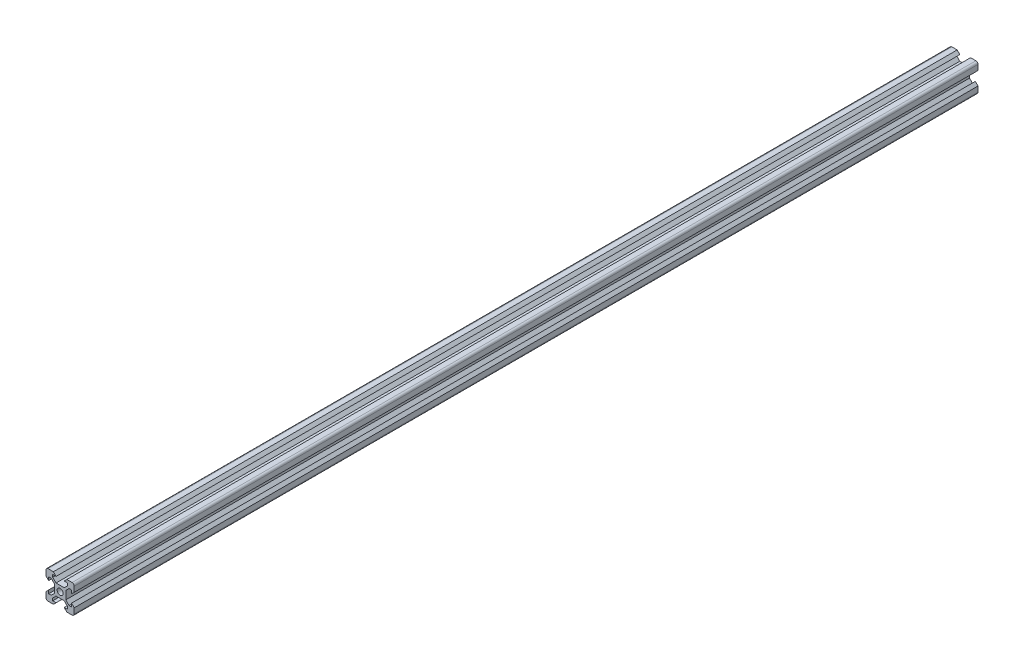
from build123d import *

# Parameters (mm, degrees)
SKETCH1_R           = 2.125
BOSS_EXTRUDE1_DEPTH = 640


with BuildPart() as part:
    # Sketch1 → Boss-Extrude1 (new body)
    with BuildSketch(Plane.XY):
        with BuildLine():
            Line((8.1, 5.225), (8.1, 2.85))
            Line((8.1, 2.85), (10, 4.75))
            Line((10, 4.75), (10, 8.5))
            ThreePointArc((10, 8.5), (9.560660172, 9.560660172), (8.5, 10))
            Line((8.5, 10), (4.75, 10))
            Line((4.75, 10), (2.85, 8.1))
            Line((2.85, 8.1), (5.225, 8.1))
            Line((5.225, 8.1), (5.225, 6.325))
            Line((5.225, 6.325), (2.9, 4))
            Line((2.9, 4), (-2.9, 4))
            Line((-2.9, 4), (-5.225, 6.325))
            Line((-5.225, 6.325), (-5.225, 8.1))
            Line((-5.225, 8.1), (-2.85, 8.1))
            Line((-2.85, 8.1), (-4.75, 10))
            Line((-4.75, 10), (-8.5, 10))
            ThreePointArc((-8.5, 10), (-9.560660172, 9.560660172), (-10, 8.5))
            Line((-10, 8.5), (-10, 4.75))
            Line((-10, 4.75), (-8.1, 2.85))
            Line((-8.1, 2.85), (-8.1, 5.225))
            Line((-8.1, 5.225), (-6.325, 5.225))
            Line((-6.325, 5.225), (-4, 2.9))
            Line((-4, 2.9), (-4, -2.9))
            Line((-4, -2.9), (-6.325, -5.225))
            Line((-6.325, -5.225), (-8.1, -5.225))
            Line((-8.1, -5.225), (-8.1, -2.85))
            Line((-8.1, -2.85), (-10, -4.75))
            Line((-10, -4.75), (-10, -8.5))
            ThreePointArc((-10, -8.5), (-9.560660172, -9.560660172), (-8.5, -10))
            Line((-8.5, -10), (-4.75, -10))
            Line((-4.75, -10), (-2.85, -8.1))
            Line((-2.85, -8.1), (-5.225, -8.1))
            Line((-5.225, -8.1), (-5.225, -6.325))
            Line((-5.225, -6.325), (-2.9, -4))
            Line((-2.9, -4), (2.9, -4))
            Line((2.9, -4), (5.225, -6.325))
            Line((5.225, -6.325), (5.225, -8.1))
            Line((5.225, -8.1), (2.85, -8.1))
            Line((2.85, -8.1), (4.75, -10))
            Line((4.75, -10), (8.5, -10))
            ThreePointArc((8.5, -10), (9.560660172, -9.560660172), (10, -8.5))
            Line((10, -8.5), (10, -4.75))
            Line((10, -4.75), (8.1, -2.85))
            Line((8.1, -2.85), (8.1, -5.225))
            Line((8.1, -5.225), (6.325, -5.225))
            Line((6.325, -5.225), (4, -2.9))
            Line((4, -2.9), (4, 2.9))
            Line((4, 2.9), (6.325, 5.225))
            Line((6.325, 5.225), (8.1, 5.225))
        make_face()
        Circle(SKETCH1_R, mode=Mode.SUBTRACT)
    extrude(amount=BOSS_EXTRUDE1_DEPTH)


solid = part.part
